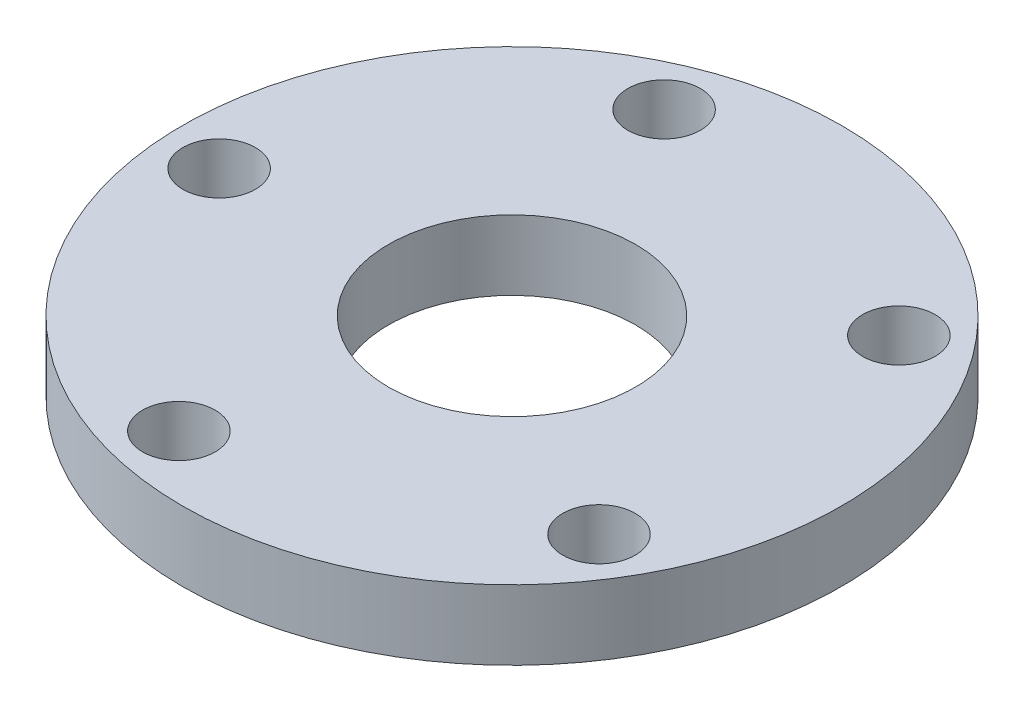
from build123d import *

# Parameters (mm, degrees)
SKETCH3_W           = 60
SKETCH3_H           = 6.35
BOSS_EXTRUDE2_DEPTH = 60
SKETCH4_R           = 11.25
CUT_EXTRUDE2_DEPTH  = 7.35
SKETCH5_R           = 3.302
CUT_EXTRUDE3_DEPTH  = 7.35
CUT_EXTRUDE4_DEPTH  = 7.35


with BuildPart() as part:
    # Sketch3 → Boss-Extrude2 (new body)
    with BuildSketch(Plane.XY):
        with Locations((30, 3.175)):
            Rectangle(SKETCH3_W, SKETCH3_H)
    extrude(amount=BOSS_EXTRUDE2_DEPTH)

    # Sketch4 → Cut-Extrude2 (cut, through all)
    with BuildSketch(Plane(origin=(0, 6.35, 0), x_dir=(1, 0, 0), z_dir=(0, 1, 0))):
        with Locations((30, -30)):
            Circle(SKETCH4_R)
    extrude(amount=-CUT_EXTRUDE2_DEPTH, mode=Mode.SUBTRACT)

    # Sketch5 → Cut-Extrude3 (cut, through all)
    with BuildSketch(Plane(origin=(0, 6.35, 0), x_dir=(1, 0, 0), z_dir=(0, 1, 0))):
        with Locations((20.658415592, -6.810890471)):
            Circle(SKETCH5_R)
        with Locations((49.167445389, -13.949796348)):
            Circle(SKETCH5_R)
        with Locations((51.187717135, -43.269538146)):
            Circle(SKETCH5_R)
        with Locations((23.927283945, -54.251229241)):
            Circle(SKETCH5_R)
        with Locations((5.059137939, -31.718545794)):
            Circle(SKETCH5_R)
    extrude(amount=-CUT_EXTRUDE3_DEPTH, mode=Mode.SUBTRACT)

    # Sketch6 → Cut-Extrude4 (cut, through all)
    with BuildSketch(Plane(origin=(0, 6.35, 0), x_dir=(1, 0, 0), z_dir=(0, 1, 0))):
        with BuildLine():
            ThreePointArc((0, -30), (8.786796564, -8.786796564), (30, 0))
            Line((30, 0), (0, 0))
            Line((0, 0), (0, -30))
        make_face()
        with BuildLine():
            Line((60, -30), (60, 0))
            Line((60, 0), (30, 0))
            ThreePointArc((30, 0), (51.213203436, -8.786796564), (60, -30))
        make_face()
        with BuildLine():
            Line((60, -60), (60, -30))
            ThreePointArc((60, -30), (51.213203436, -51.213203436), (30, -60))
            Line((30, -60), (60, -60))
        make_face()
        with BuildLine():
            ThreePointArc((30, -60), (8.786796564, -51.213203436), (0, -30))
            Line((0, -30), (0, -60))
            Line((0, -60), (30, -60))
        make_face()
    extrude(amount=-CUT_EXTRUDE4_DEPTH, mode=Mode.SUBTRACT)


solid = part.part
